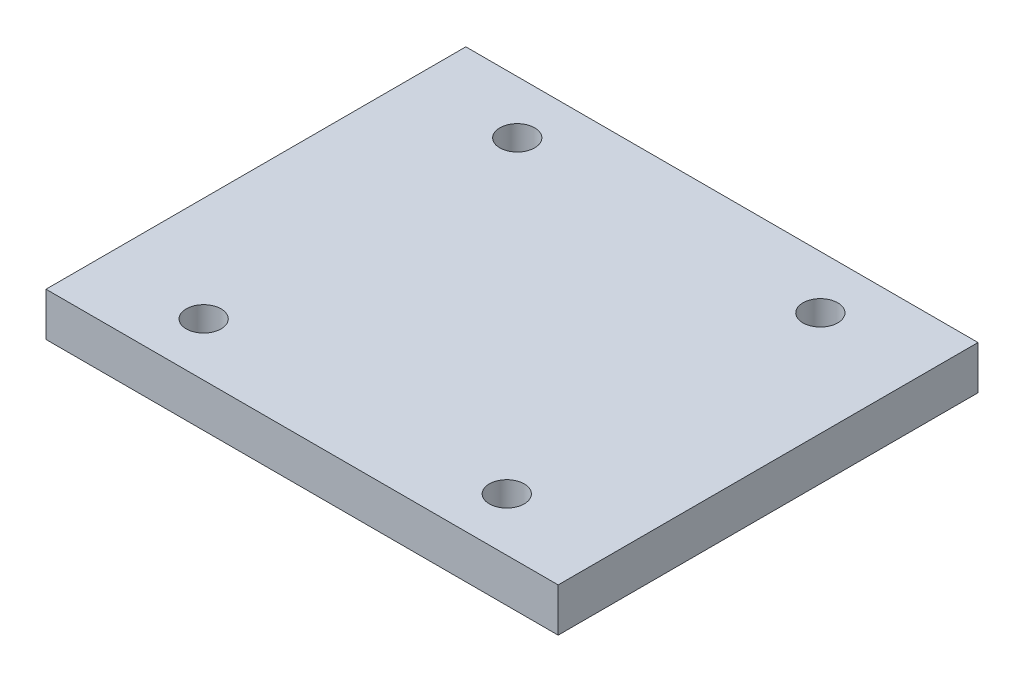
from build123d import *

# Parameters (mm, degrees)
SKETCH1_W           = 29.4
SKETCH1_H           = 23.1
SKETCH1_R           = 1
BOSS_EXTRUDE1_DEPTH = 2.5
SKETCH2_W           = 29.4
SKETCH2_H           = 2.5
BOSS_EXTRUDE2_DEPTH = 0.5
SKETCH3_W           = 29.4
SKETCH3_H           = 2.5
BOSS_EXTRUDE3_DEPTH = 0.5


with BuildPart() as part:
    # Sketch1 → Boss-Extrude1 (new body)
    with BuildSketch(Plane(origin=(0, 0, 0), x_dir=(1, 0, 0), z_dir=(0, 1, 0))):
        with Locations((-0.8, -0.45)):
            Rectangle(SKETCH1_W, SKETCH1_H)
        with Locations((-9.5, 8.55)):
            Circle(SKETCH1_R, mode=Mode.SUBTRACT)
        with Locations((7.9, 8.55)):
            Circle(SKETCH1_R, mode=Mode.SUBTRACT)
        with Locations((7.9, -9.45)):
            Circle(SKETCH1_R, mode=Mode.SUBTRACT)
        with Locations((-9.5, -9.45)):
            Circle(SKETCH1_R, mode=Mode.SUBTRACT)
    extrude(amount=BOSS_EXTRUDE1_DEPTH)

    # Sketch2 → Boss-Extrude2 (add)
    with BuildSketch(Plane(origin=(0, 0, -11.1), x_dir=(-1, 0, 0), z_dir=(0, 0, -1))):
        with Locations((0.8, 1.25)):
            Rectangle(SKETCH2_W, SKETCH2_H)
    extrude(amount=BOSS_EXTRUDE2_DEPTH)

    # Sketch3 → Boss-Extrude3 (add)
    with BuildSketch(Plane.XY.offset(12)):
        with Locations((-0.8, 1.25)):
            Rectangle(SKETCH3_W, SKETCH3_H)
    extrude(amount=BOSS_EXTRUDE3_DEPTH)


solid = part.part
